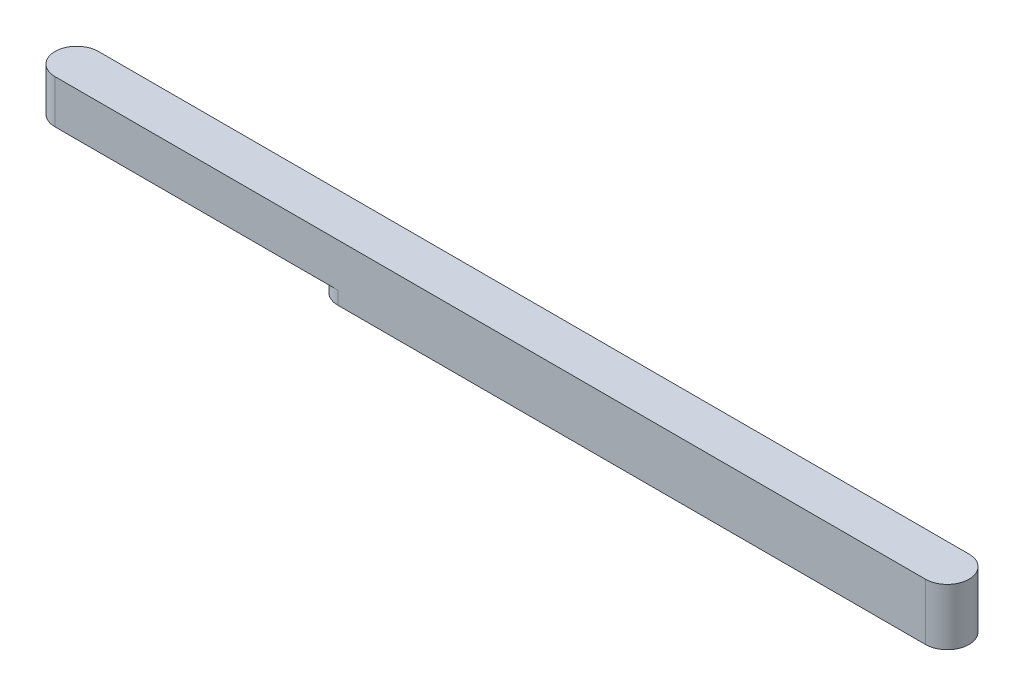
from build123d import *

# Parameters (mm, degrees)
EXTRUDE_1_DEPTH     = 5
SKETCH_3_R          = 0.515
SKETCH_3_R_2        = 1
SKETCH_3_R_3        = 2.345
CUT_EXTRUDE_1_DEPTH = 6
EXTRUDE_2_DEPTH     = 3
CUT_EXTRUDE_2_DEPTH = 10


with BuildPart() as part:
    # 스케치1 → 보스-돌출1 (new body, symmetric)
    with BuildSketch(Plane(origin=(0, 0, 0), x_dir=(1, 0, 0), z_dir=(0, 1, 0))):
        with BuildLine():
            Line((-100, 5), (100, 5))
            ThreePointArc((100, 5), (105, 0), (100, -5))
            Line((100, -5), (-100, -5))
            ThreePointArc((-100, -5), (-105, 0), (-100, 5))
        make_face()
    extrude(amount=EXTRUDE_1_DEPTH, both=True)

    # 스케치3 → 컷-돌출1 (cut)
    with BuildSketch(Plane.XZ.offset(5)):
        with Locations((-90, 0)):
            Circle(SKETCH_3_R)
        with Locations((-88.036, 0)):
            Circle(SKETCH_3_R_2)
        with Locations((-86.072, 0)):
            Circle(SKETCH_3_R)
        with Locations((-84.108, 0)):
            Circle(SKETCH_3_R_2)
        with Locations((-82.144, 0)):
            Circle(SKETCH_3_R)
        with Locations((-80.18, 0)):
            Circle(SKETCH_3_R)
        with Locations((-75.93, 0)):
            Circle(SKETCH_3_R_3)
        with Locations((-71.68, 0)):
            Circle(SKETCH_3_R)
        with Locations((-69.716, 0)):
            Circle(SKETCH_3_R)
        with Locations((-67.752, 0)):
            Circle(SKETCH_3_R_2)
        with Locations((-65.788, 0)):
            Circle(SKETCH_3_R)
        with Locations((-61.86, 0)):
            Circle(SKETCH_3_R)
        with Locations((-63.824, 0)):
            Circle(SKETCH_3_R_2)
    extrude(amount=-CUT_EXTRUDE_1_DEPTH, mode=Mode.SUBTRACT)

    # 스케치5 → 보스-돌출2 (add)
    with BuildSketch(Plane.XZ.offset(5)):
        with BuildLine():
            Line((100, -5), (-35, -5))
            ThreePointArc((-35, -5), (-40, 0), (-35, 5))
            Line((-35, 5), (100, 5))
            ThreePointArc((100, 5), (105, 0), (100, -5))
        make_face()
    extrude(amount=EXTRUDE_2_DEPTH)

    # 스케치6 → 컷-돌출2 (cut)
    with BuildSketch(Plane.XZ.offset(8)):
        with BuildLine():
            Line((-35, 3), (100, 3))
            ThreePointArc((100, 3), (103, 0), (100, -3))
            Line((100, -3), (-35, -3))
            ThreePointArc((-35, -3), (-38, 0), (-35, 3))
        make_face()
    extrude(amount=-CUT_EXTRUDE_2_DEPTH, mode=Mode.SUBTRACT)


solid = part.part
